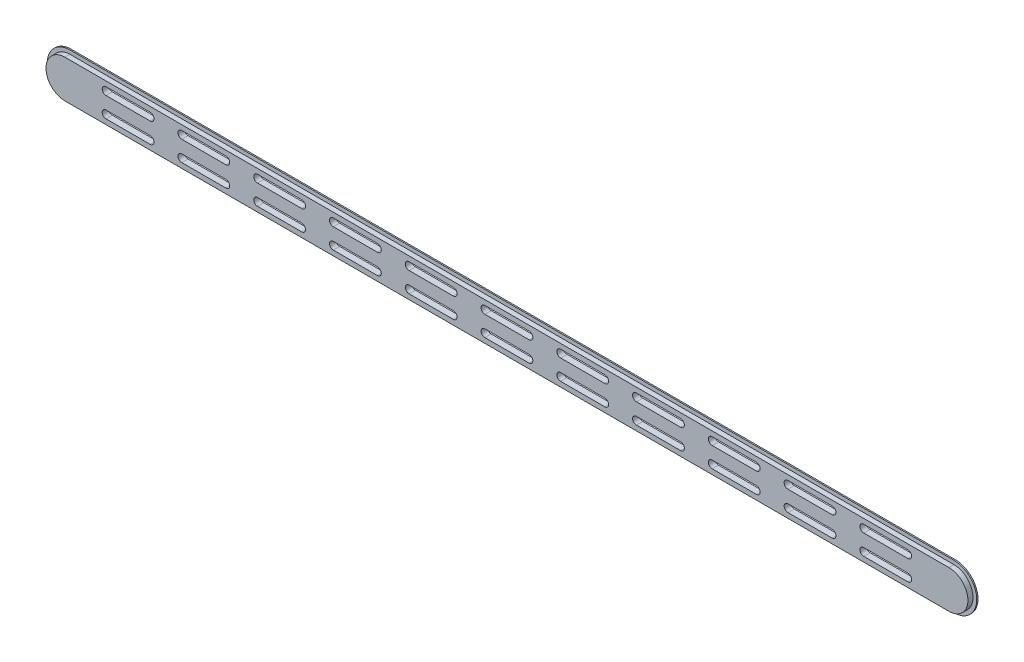
from build123d import *

# Parameters (mm, degrees)
BOSS_EXTRUDE4_DEPTH   = 1
BOSS_EXTRUDE5_DEPTH   = 4
CUT_EXTRUDE3_DEPTH    = 6
LPATTERN1_COUNT       = 11
LPATTERN1_PITCH       = 60
MIRROR1_COPY_1_DEPTH  = 6
MIRROR1_COPY_2_DEPTH  = 6
MIRROR1_COPY_3_DEPTH  = 6
MIRROR1_COPY_4_DEPTH  = 6
MIRROR1_COPY_5_DEPTH  = 6
MIRROR1_COPY_6_DEPTH  = 6
MIRROR1_COPY_7_DEPTH  = 6
MIRROR1_COPY_8_DEPTH  = 6
MIRROR1_COPY_9_DEPTH  = 6
MIRROR1_COPY_10_DEPTH = 6


with BuildPart() as part:
    # Sketch3 → Boss-Extrude4 (new body)
    with BuildSketch(Plane.XY):
        with BuildLine():
            Line((-350, 18), (350, 18))
            ThreePointArc((350, 18), (368, 0), (350, -18))
            Line((350, -18), (-350, -18))
            ThreePointArc((-350, -18), (-368, 0), (-350, 18))
        make_face()
    extrude(amount=BOSS_EXTRUDE4_DEPTH)

    # Sketch4 → Boss-Extrude5 (add)
    with BuildSketch(Plane.XY.offset(1)):
        with BuildLine():
            Line((-350, 15), (350, 15))
            ThreePointArc((350, 15), (365, 0), (350, -15))
            Line((350, -15), (-350, -15))
            ThreePointArc((-350, -15), (-365, 0), (-350, 15))
        make_face()
    extrude(amount=BOSS_EXTRUDE5_DEPTH)

    # Sketch5 → Cut-Extrude3 (cut, through all)
    with BuildSketch(Plane.XY.offset(5)):
        with BuildLine():
            Line((-317.5, 11), (-282.5, 11))
            ThreePointArc((-282.5, 11), (-279.5, 8), (-282.5, 5))
            Line((-282.5, 5), (-317.5, 5))
            ThreePointArc((-317.5, 5), (-320.5, 8), (-317.5, 11))
        make_face()
    cut_extrude3 = extrude(amount=-CUT_EXTRUDE3_DEPTH, mode=Mode.SUBTRACT)

    # LPattern1: Cut-Extrude3 ×11
    with Locations(*[(i * LPATTERN1_PITCH, 0, 0) for i in range(1, LPATTERN1_COUNT)]):
        add(cut_extrude3, mode=Mode.SUBTRACT)

    # Mirror1: Cut-Extrude3 across plane
    add(cut_extrude3.mirror(Plane.ZX), mode=Mode.SUBTRACT)

    # Mirror1 copy 1 sketch → Mirror1 copy 1 (cut, through all)
    with BuildSketch(Plane(origin=(60, 0, 5), x_dir=(1, 0, 0), z_dir=(0, 0, 1))):
        with BuildLine():
            Line((-317.5, -11), (-282.5, -11))
            ThreePointArc((-282.5, -11), (-279.5, -8), (-282.5, -5))
            Line((-282.5, -5), (-317.5, -5))
            ThreePointArc((-317.5, -5), (-320.5, -8), (-317.5, -11))
        make_face()
    extrude(amount=-MIRROR1_COPY_1_DEPTH, mode=Mode.SUBTRACT)

    # Mirror1 copy 2 sketch → Mirror1 copy 2 (cut, through all)
    with BuildSketch(Plane(origin=(120, 0, 5), x_dir=(1, 0, 0), z_dir=(0, 0, 1))):
        with BuildLine():
            Line((-317.5, -11), (-282.5, -11))
            ThreePointArc((-282.5, -11), (-279.5, -8), (-282.5, -5))
            Line((-282.5, -5), (-317.5, -5))
            ThreePointArc((-317.5, -5), (-320.5, -8), (-317.5, -11))
        make_face()
    extrude(amount=-MIRROR1_COPY_2_DEPTH, mode=Mode.SUBTRACT)

    # Mirror1 copy 3 sketch → Mirror1 copy 3 (cut, through all)
    with BuildSketch(Plane(origin=(180, 0, 5), x_dir=(1, 0, 0), z_dir=(0, 0, 1))):
        with BuildLine():
            Line((-317.5, -11), (-282.5, -11))
            ThreePointArc((-282.5, -11), (-279.5, -8), (-282.5, -5))
            Line((-282.5, -5), (-317.5, -5))
            ThreePointArc((-317.5, -5), (-320.5, -8), (-317.5, -11))
        make_face()
    extrude(amount=-MIRROR1_COPY_3_DEPTH, mode=Mode.SUBTRACT)

    # Mirror1 copy 4 sketch → Mirror1 copy 4 (cut, through all)
    with BuildSketch(Plane(origin=(240, 0, 5), x_dir=(1, 0, 0), z_dir=(0, 0, 1))):
        with BuildLine():
            Line((-317.5, -11), (-282.5, -11))
            ThreePointArc((-282.5, -11), (-279.5, -8), (-282.5, -5))
            Line((-282.5, -5), (-317.5, -5))
            ThreePointArc((-317.5, -5), (-320.5, -8), (-317.5, -11))
        make_face()
    extrude(amount=-MIRROR1_COPY_4_DEPTH, mode=Mode.SUBTRACT)

    # Mirror1 copy 5 sketch → Mirror1 copy 5 (cut, through all)
    with BuildSketch(Plane(origin=(300, 0, 5), x_dir=(1, 0, 0), z_dir=(0, 0, 1))):
        with BuildLine():
            Line((-317.5, -11), (-282.5, -11))
            ThreePointArc((-282.5, -11), (-279.5, -8), (-282.5, -5))
            Line((-282.5, -5), (-317.5, -5))
            ThreePointArc((-317.5, -5), (-320.5, -8), (-317.5, -11))
        make_face()
    extrude(amount=-MIRROR1_COPY_5_DEPTH, mode=Mode.SUBTRACT)

    # Mirror1 copy 6 sketch → Mirror1 copy 6 (cut, through all)
    with BuildSketch(Plane(origin=(360, 0, 5), x_dir=(1, 0, 0), z_dir=(0, 0, 1))):
        with BuildLine():
            Line((-317.5, -11), (-282.5, -11))
            ThreePointArc((-282.5, -11), (-279.5, -8), (-282.5, -5))
            Line((-282.5, -5), (-317.5, -5))
            ThreePointArc((-317.5, -5), (-320.5, -8), (-317.5, -11))
        make_face()
    extrude(amount=-MIRROR1_COPY_6_DEPTH, mode=Mode.SUBTRACT)

    # Mirror1 copy 7 sketch → Mirror1 copy 7 (cut, through all)
    with BuildSketch(Plane(origin=(420, 0, 5), x_dir=(1, 0, 0), z_dir=(0, 0, 1))):
        with BuildLine():
            Line((-317.5, -11), (-282.5, -11))
            ThreePointArc((-282.5, -11), (-279.5, -8), (-282.5, -5))
            Line((-282.5, -5), (-317.5, -5))
            ThreePointArc((-317.5, -5), (-320.5, -8), (-317.5, -11))
        make_face()
    extrude(amount=-MIRROR1_COPY_7_DEPTH, mode=Mode.SUBTRACT)

    # Mirror1 copy 8 sketch → Mirror1 copy 8 (cut, through all)
    with BuildSketch(Plane(origin=(480, 0, 5), x_dir=(1, 0, 0), z_dir=(0, 0, 1))):
        with BuildLine():
            Line((-317.5, -11), (-282.5, -11))
            ThreePointArc((-282.5, -11), (-279.5, -8), (-282.5, -5))
            Line((-282.5, -5), (-317.5, -5))
            ThreePointArc((-317.5, -5), (-320.5, -8), (-317.5, -11))
        make_face()
    extrude(amount=-MIRROR1_COPY_8_DEPTH, mode=Mode.SUBTRACT)

    # Mirror1 copy 9 sketch → Mirror1 copy 9 (cut, through all)
    with BuildSketch(Plane(origin=(540, 0, 5), x_dir=(1, 0, 0), z_dir=(0, 0, 1))):
        with BuildLine():
            Line((-317.5, -11), (-282.5, -11))
            ThreePointArc((-282.5, -11), (-279.5, -8), (-282.5, -5))
            Line((-282.5, -5), (-317.5, -5))
            ThreePointArc((-317.5, -5), (-320.5, -8), (-317.5, -11))
        make_face()
    extrude(amount=-MIRROR1_COPY_9_DEPTH, mode=Mode.SUBTRACT)

    # Mirror1 copy 10 sketch → Mirror1 copy 10 (cut, through all)
    with BuildSketch(Plane(origin=(600, 0, 5), x_dir=(1, 0, 0), z_dir=(0, 0, 1))):
        with BuildLine():
            Line((-317.5, -11), (-282.5, -11))
            ThreePointArc((-282.5, -11), (-279.5, -8), (-282.5, -5))
            Line((-282.5, -5), (-317.5, -5))
            ThreePointArc((-317.5, -5), (-320.5, -8), (-317.5, -11))
        make_face()
    extrude(amount=-MIRROR1_COPY_10_DEPTH, mode=Mode.SUBTRACT)


solid = part.part
